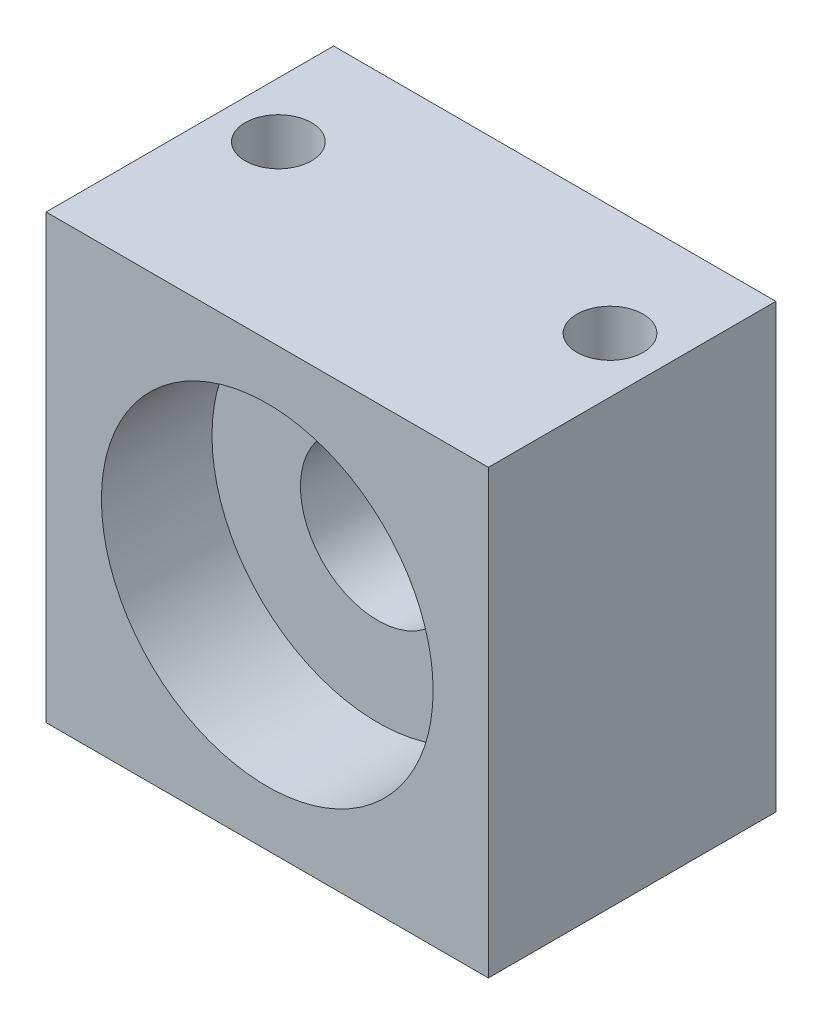
from build123d import *

# Parameters (mm, degrees)
ESQUISSE1_W             = 20
ESQUISSE1_H             = 20
BOSS_EXTRU_1_DEPTH      = 13
ESQUISSE2_R             = 7.5
ENL_V_MAT_EXTRU_1_DEPTH = 5
ESQUISSE3_R             = 3.5
ENL_V_MAT_EXTRU_2_DEPTH = 5
ESQUISSE4_R             = 1.5
ENL_V_MAT_EXTRU_3_DEPTH = 21


with BuildPart() as part:
    # Esquisse1 → Boss.-Extru.1 (new body)
    with BuildSketch(Plane.XY):
        with Locations((10, 10)):
            Rectangle(ESQUISSE1_W, ESQUISSE1_H)
    extrude(amount=BOSS_EXTRU_1_DEPTH)

    # Esquisse2 → Enlèv. mat.-Extru.1 (cut)
    with BuildSketch(Plane.XY.offset(13)):
        with Locations((10, 10)):
            Circle(ESQUISSE2_R)
    extrude(amount=-ENL_V_MAT_EXTRU_1_DEPTH, mode=Mode.SUBTRACT)

    # Esquisse3 → Enlèv. mat.-Extru.2 (cut)
    with BuildSketch(Plane.XY.offset(8)):
        with Locations((10, 10)):
            Circle(ESQUISSE3_R)
    extrude(amount=-ENL_V_MAT_EXTRU_2_DEPTH, mode=Mode.SUBTRACT)

    # Esquisse4 → Enlèv. mat.-Extru.3 (cut, through all)
    with BuildSketch(Plane(origin=(0, 20, 0), x_dir=(1, 0, 0), z_dir=(0, 1, 0))):
        with Locations((17.5, -5)):
            Circle(ESQUISSE4_R)
        with Locations((2.5, -5)):
            Circle(ESQUISSE4_R)
    extrude(amount=-ENL_V_MAT_EXTRU_3_DEPTH, mode=Mode.SUBTRACT)


solid = part.part
